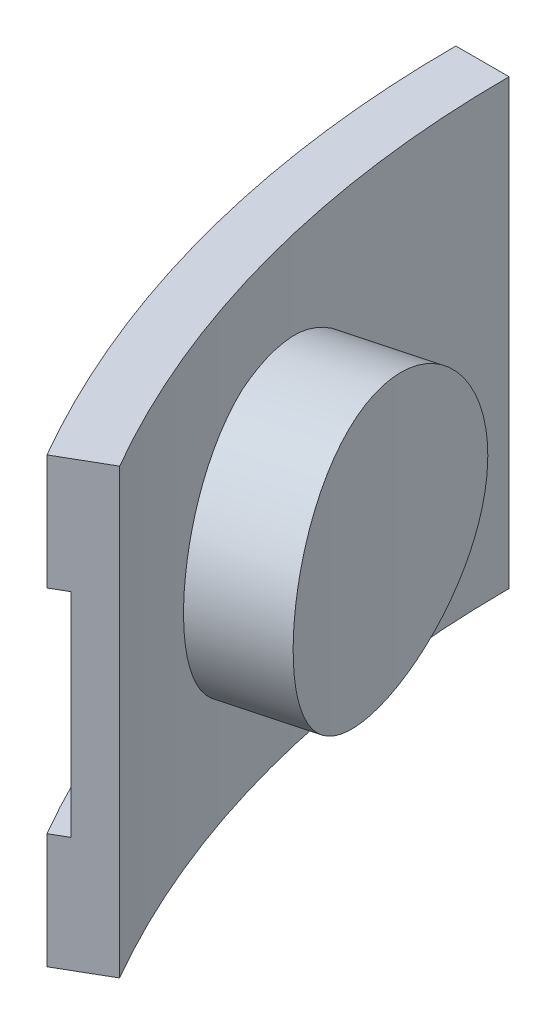
from build123d import *

# Parameters (mm, degrees)
REVOLVE1_ANGLE      = 30
SKETCH2_R           = 9.85774
BOSS_EXTRUDE1_DEPTH = 2.54
SKETCH3_R           = 9.85774
BOSS_EXTRUDE2_DEPTH = 12.7
SKETCH4_W           = 69.85
SKETCH4_H           = 31.75
CUT_REVOLVE1_ANGLE  = 30


with BuildPart() as part:
    # Sketch1 → Revolve1 (revolve)
    with BuildSketch(Plane.XY):
        Polygon((-80.01, 0), (-80.01, 8.255), (-78.74, 8.255), (-78.74, 23.495), (-80.01, 23.495), (-80.01, 31.75), (-76.2, 31.75), (-76.2, 0), align=None)
    revolve(axis=Axis((0, 0, 0), (0, 1, 0)), revolution_arc=REVOLVE1_ANGLE)

    # Sketch2 → Boss-Extrude1 (add)
    with BuildSketch(Plane(origin=(-71.095567884, 0, 19.05), x_dir=(0.258819045, 0, 0.965925826), z_dir=(-0.965925826, 0, 0.258819045))):
        with Locations((0, 15.875)):
            Circle(SKETCH2_R)
    extrude(amount=BOSS_EXTRUDE1_DEPTH)

    # Sketch3 → Boss-Extrude2 (add)
    with BuildSketch(Plane(origin=(-71.095567884, 0, 19.05), x_dir=(-0.258819045, 0, -0.965925826), z_dir=(0.965925826, 0, -0.258819045))):
        with Locations((0, 15.875)):
            Circle(SKETCH3_R)
    extrude(amount=BOSS_EXTRUDE2_DEPTH)

    # Sketch4 → Cut-Revolve1 (revolve, cut)
    with BuildSketch(Plane.XY):
        with Locations((-34.925, 15.875)):
            Rectangle(SKETCH4_W, SKETCH4_H)
    revolve(axis=Axis((0, 0, 0), (0, 1, 0)), revolution_arc=CUT_REVOLVE1_ANGLE, mode=Mode.SUBTRACT)


solid = part.part
